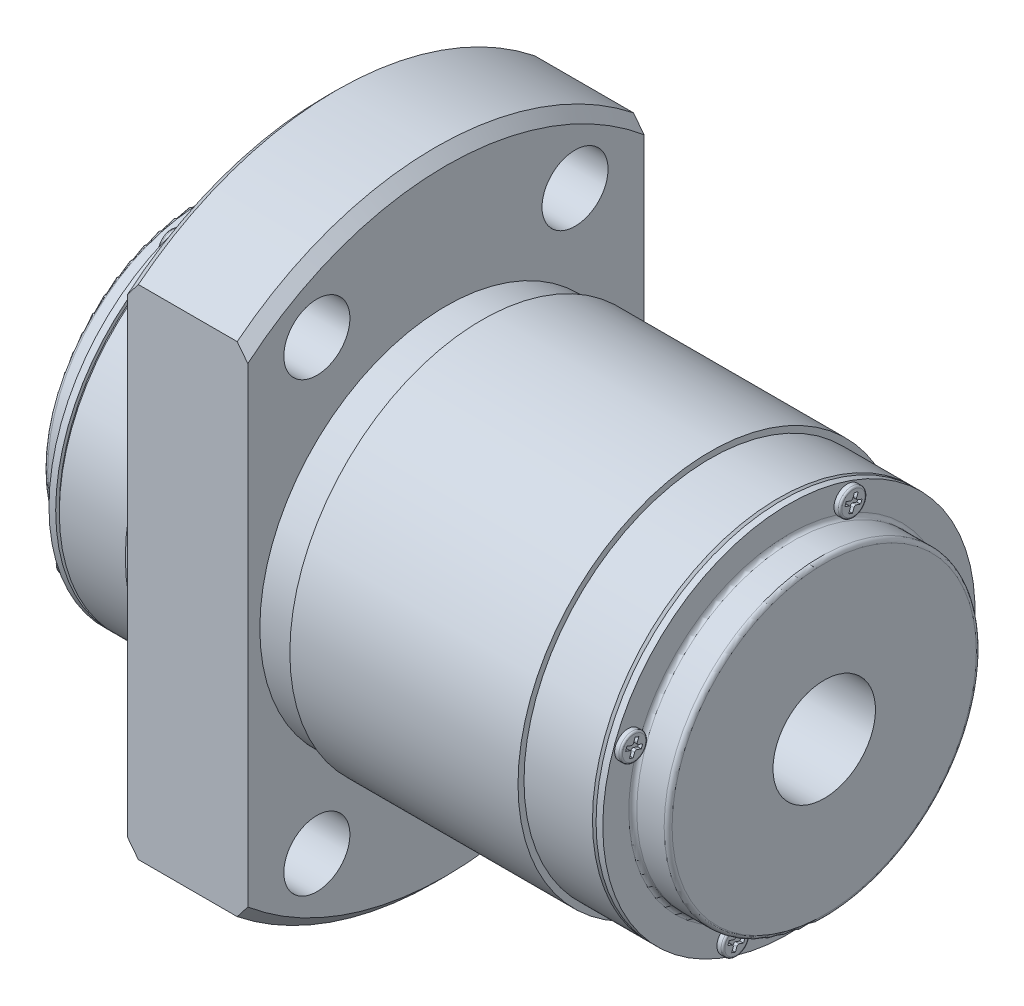
from build123d import *

# Parameters (mm, degrees)
SKETCH2_W           = 10
SKETCH2_H           = 2.75
SKETCH3_W           = 10
SKETCH3_H           = 2.75
SKETCH4_W           = 10
SKETCH4_H           = 2.75
SKETCH5_W           = 10
SKETCH5_H           = 2.75
SKETCH7_W           = 66
SKETCH7_H           = 106
SKETCH7_W_2         = 33
SKETCH7_H_2         = 55
CUT_EXTRUDE1_DEPTH  = 10
CUT_EXTRUDE2_DEPTH  = 0.3
CUT_EXTRUDE3_DEPTH  = 0.3
CUT_EXTRUDE4_DEPTH  = 0.3
CUT_EXTRUDE5_DEPTH  = 0.3
CUT_EXTRUDE6_DEPTH  = 0.3
CUT_EXTRUDE7_DEPTH  = 0.3
CUT_EXTRUDE8_DEPTH  = 0.3
CUT_EXTRUDE9_DEPTH  = 0.3
SKETCH24_R          = 7.5
SKETCH24_R_2        = 4.266666667
BOSS_EXTRUDE1_DEPTH = 52
SCALE1_SCALE        = 7.5


with BuildPart() as part:
    # Sketch1 → Revolve1 (revolve)
    with BuildSketch(Plane.XY):
        with BuildLine():
            Line((-3.5, 7.5), (48.5, 7.5))
            Line((48.5, 7.5), (48.5, 12.67))
            ThreePointArc((48.5, 12.67), (48.403345238, 12.903345238), (48.17, 13))
            Line((48.17, 13), (45.89, 13))
            ThreePointArc((45.89, 13), (45.656654762, 13.096654762), (45.56, 13.33))
            Line((45.56, 13.33), (45.56, 15.5))
            Line((45.56, 15.5), (45, 15.5))
            Line((45, 15.5), (45, 15.2))
            Line((45, 15.2), (44.7, 15.5))
            Line((44.7, 15.5), (39, 15.5))
            Line((39, 15.5), (39, 16))
            Line((39, 16), (20, 16))
            Line((20, 16), (20, 15.5))
            Line((20, 15.5), (17, 15.5))
            Line((17, 15.5), (17, 25.616666667))
            Line((17, 25.616666667), (16.116666667, 26.5))
            Line((16.116666667, 26.5), (7.883333333, 26.5))
            Line((7.883333333, 26.5), (7, 25.616666667))
            Line((7, 25.616666667), (7, 16))
            Line((7, 16), (6.3, 16))
            Line((6.3, 16), (6.3, 15.5))
            Line((6.3, 15.5), (0.3, 15.5))
            Line((0.3, 15.5), (0, 15.2))
            Line((0, 15.2), (0, 15.5))
            Line((0, 15.5), (-0.56, 15.5))
            Line((-0.56, 15.5), (-0.56, 13.33))
            ThreePointArc((-0.56, 13.33), (-0.656654762, 13.096654762), (-0.89, 13))
            Line((-0.89, 13), (-3.17, 13))
            ThreePointArc((-3.17, 13), (-3.403345238, 12.903345238), (-3.5, 12.67))
            Line((-3.5, 12.67), (-3.5, 7.5))
        make_face()
    revolve(axis=Axis((45, 0, 0), (-1, 0, 0)))

    # Sketch2 → Cut-Revolve1 (revolve, cut)
    with BuildSketch(Plane(origin=(0, 0, 0), x_dir=(1, 0, 0), z_dir=(0, -0.5, 0.866025404))):
        with Locations((12, 22.875)):
            Rectangle(SKETCH2_W, SKETCH2_H)
    revolve(axis=Axis((17, 18.619546181, 10.75), (-1, 0, 0)), mode=Mode.SUBTRACT)

    # Sketch3 → Cut-Revolve2 (revolve, cut)
    with BuildSketch(Plane(origin=(0, 0, 0), x_dir=(1, 0, 0), z_dir=(0, -0.5, 0.866025404))):
        with Locations((12, -20.125)):
            Rectangle(SKETCH3_W, SKETCH3_H)
    revolve(axis=Axis((17, -18.619546181, -10.75), (-1, 0, 0)), mode=Mode.SUBTRACT)

    # Sketch4 → Cut-Revolve3 (revolve, cut)
    with BuildSketch(Plane(origin=(0, 0, 0), x_dir=(1, 0, 0), z_dir=(0, 0.5, 0.866025404))):
        with Locations((12, 22.875)):
            Rectangle(SKETCH4_W, SKETCH4_H)
    revolve(axis=Axis((17, 18.619546181, -10.75), (-1, 0, 0)), mode=Mode.SUBTRACT)

    # Sketch5 → Cut-Revolve4 (revolve, cut)
    with BuildSketch(Plane(origin=(0, 0, 0), x_dir=(1, 0, 0), z_dir=(0, 0.5, 0.866025404))):
        with Locations((12, -20.125)):
            Rectangle(SKETCH5_W, SKETCH5_H)
    revolve(axis=Axis((17, -18.619546181, 10.75), (-1, 0, 0)), mode=Mode.SUBTRACT)

    # Sketch6 → Cut-Revolve5 (revolve, cut)
    with BuildSketch(Plane.XY):
        Polygon((12, -5.5), (14.4585, -6.919415637), (14.4585, -25.9585), (15, -26.5), (12, -26.5), align=None)
    revolve(axis=Axis((12, -26.5, 0), (0, 1, 0)), mode=Mode.SUBTRACT)

    # Sketch7 → Cut-Extrude1 (cut)
    with BuildSketch(Plane(origin=(17, 0, 0), x_dir=(0, 0, -1), z_dir=(1, 0, 0))):
        Rectangle(SKETCH7_W, SKETCH7_H)
        Rectangle(SKETCH7_W_2, SKETCH7_H_2, mode=Mode.SUBTRACT)
    extrude(amount=-CUT_EXTRUDE1_DEPTH, mode=Mode.SUBTRACT)

    # Sketch8 → Revolve2 (revolve)
    with BuildSketch(Plane(origin=(0, 0, 0), x_dir=(1, 0, 0), z_dir=(0, -0.342020143, 0.939692621))):
        with BuildLine():
            Line((-1.06, 14.25), (-1.06, 15.17))
            ThreePointArc((-1.06, 15.17), (-1.001421356, 15.311421356), (-0.86, 15.37))
            Line((-0.86, 15.37), (-0.56, 15.37))
            Line((-0.56, 15.37), (-0.56, 14.25))
            Line((-0.56, 14.25), (-1.06, 14.25))
        make_face()
    revolve(axis=Axis((-0.56, 13.390619846, 4.873787042), (-1, 0, 0)))

    # Sketch9 → Revolve3 (revolve)
    with BuildSketch(Plane(origin=(0, -4.873787042, 13.390619846), x_dir=(1, 0, 0), z_dir=(0, -0.342020143, 0.939692621))):
        with BuildLine():
            Line((-1.06, 0), (-1.06, 0.92))
            ThreePointArc((-1.06, 0.92), (-1.001421356, 1.061421356), (-0.86, 1.12))
            Line((-0.86, 1.12), (-0.56, 1.12))
            Line((-0.56, 1.12), (-0.56, 0))
            Line((-0.56, 0), (-1.06, 0))
        make_face()
    revolve(axis=Axis((-0.56, -4.873787042, 13.390619846), (-1, 0, 0)))

    # Sketch10 → Revolve4 (revolve)
    with BuildSketch(Plane(origin=(0, 0, 0), x_dir=(1, 0, 0), z_dir=(0, -0.342020143, 0.939692621))):
        with BuildLine():
            Line((-1.06, -14.25), (-1.06, -13.33))
            ThreePointArc((-1.06, -13.33), (-1.001421356, -13.188578644), (-0.86, -13.13))
            Line((-0.86, -13.13), (-0.56, -13.13))
            Line((-0.56, -13.13), (-0.56, -14.25))
            Line((-0.56, -14.25), (-1.06, -14.25))
        make_face()
    revolve(axis=Axis((-0.56, -13.390619846, -4.873787042), (-1, 0, 0)))

    # Sketch11 → Revolve5 (revolve)
    with BuildSketch(Plane(origin=(0, 4.873787042, -13.390619846), x_dir=(1, 0, 0), z_dir=(0, -0.342020143, 0.939692621))):
        with BuildLine():
            Line((-1.06, 0), (-1.06, 0.92))
            ThreePointArc((-1.06, 0.92), (-1.001421356, 1.061421356), (-0.86, 1.12))
            Line((-0.86, 1.12), (-0.56, 1.12))
            Line((-0.56, 1.12), (-0.56, 0))
            Line((-0.56, 0), (-1.06, 0))
        make_face()
    revolve(axis=Axis((-0.56, 4.873787042, -13.390619846), (-1, 0, 0)))

    # Sketch12 → Revolve6 (revolve)
    with BuildSketch(Plane(origin=(0, 0, 0), x_dir=(1, 0, 0), z_dir=(0, 0.342020143, 0.939692621))):
        with BuildLine():
            Line((45.56, 14.25), (45.56, 15.37))
            Line((45.56, 15.37), (45.91, 15.37))
            ThreePointArc((45.91, 15.37), (46.016066017, 15.326066017), (46.06, 15.22))
            Line((46.06, 15.22), (46.06, 14.25))
            Line((46.06, 14.25), (45.56, 14.25))
        make_face()
    revolve(axis=Axis((46.06, 13.390619846, -4.873787042), (-1, 0, 0)))

    # Sketch13 → Revolve7 (revolve)
    with BuildSketch(Plane(origin=(0, -4.873787042, -13.390619846), x_dir=(1, 0, 0), z_dir=(0, 0.342020143, 0.939692621))):
        with BuildLine():
            Line((45.56, 0), (45.56, 1.12))
            Line((45.56, 1.12), (45.91, 1.12))
            ThreePointArc((45.91, 1.12), (46.016066017, 1.076066017), (46.06, 0.97))
            Line((46.06, 0.97), (46.06, 0))
            Line((46.06, 0), (45.56, 0))
        make_face()
    revolve(axis=Axis((46.06, -4.873787042, -13.390619846), (-1, 0, 0)))

    # Sketch14 → Revolve8 (revolve)
    with BuildSketch(Plane(origin=(0, 0, 0), x_dir=(1, 0, 0), z_dir=(0, 0.342020143, 0.939692621))):
        with BuildLine():
            Line((45.56, -14.25), (45.56, -13.13))
            Line((45.56, -13.13), (45.91, -13.13))
            ThreePointArc((45.91, -13.13), (46.016066017, -13.173933983), (46.06, -13.28))
            Line((46.06, -13.28), (46.06, -14.25))
            Line((46.06, -14.25), (45.56, -14.25))
        make_face()
    revolve(axis=Axis((46.06, -13.390619846, 4.873787042), (-1, 0, 0)))

    # Sketch15 → Revolve9 (revolve)
    with BuildSketch(Plane(origin=(0, 4.873787042, 13.390619846), x_dir=(1, 0, 0), z_dir=(0, 0.342020143, 0.939692621))):
        with BuildLine():
            Line((45.56, 0), (45.56, 1.12))
            Line((45.56, 1.12), (45.91, 1.12))
            ThreePointArc((45.91, 1.12), (46.016066017, 1.076066017), (46.06, 0.97))
            Line((46.06, 0.97), (46.06, 0))
            Line((46.06, 0), (45.56, 0))
        make_face()
    revolve(axis=Axis((46.06, 4.873787042, 13.390619846), (-1, 0, 0)))

    # Sketch16 → Cut-Extrude2 (cut)
    with BuildSketch(Plane(origin=(46.06, 0, 0), x_dir=(0, 0, -1), z_dir=(1, 0, 0))):
        with BuildLine():
            Line((4.164267347, 13.473274563), (4.511953617, 13.34672711))
            ThreePointArc((4.511953617, 13.34672711), (4.60223964, 13.263995213), (4.607581213, 13.141653068))
            Line((4.607581213, 13.141653068), (4.48103376, 12.793966798))
            Line((4.48103376, 12.793966798), (4.791132325, 12.681100151))
            Line((4.791132325, 12.681100151), (4.917679778, 13.028786421))
            ThreePointArc((4.917679778, 13.028786421), (5.000411676, 13.119072444), (5.12275382, 13.124414017))
            Line((5.12275382, 13.124414017), (5.47044009, 12.997866564))
            Line((5.47044009, 12.997866564), (5.583306737, 13.307965129))
            Line((5.583306737, 13.307965129), (5.235620468, 13.434512582))
            ThreePointArc((5.235620468, 13.434512582), (5.145334445, 13.517244479), (5.139992871, 13.639586624))
            Line((5.139992871, 13.639586624), (5.266540324, 13.987272894))
            Line((5.266540324, 13.987272894), (4.95644176, 14.100139541))
            Line((4.95644176, 14.100139541), (4.829894307, 13.752453272))
            ThreePointArc((4.829894307, 13.752453272), (4.747162409, 13.662167249), (4.624820264, 13.656825675))
            Line((4.624820264, 13.656825675), (4.277133995, 13.783373128))
            Line((4.277133995, 13.783373128), (4.164267347, 13.473274563))
        make_face()
    extrude(amount=-CUT_EXTRUDE2_DEPTH, mode=Mode.SUBTRACT)

    # Sketch17 → Cut-Extrude3 (cut)
    with BuildSketch(Plane(origin=(46.06, 0, 0), x_dir=(0, 0, -1), z_dir=(1, 0, 0))):
        with BuildLine():
            Line((-14.100139541, 4.95644176), (-13.752453272, 4.829894307))
            ThreePointArc((-13.752453272, 4.829894307), (-13.662167249, 4.747162409), (-13.656825675, 4.624820264))
            Line((-13.656825675, 4.624820264), (-13.783373128, 4.277133995))
            Line((-13.783373128, 4.277133995), (-13.473274563, 4.164267347))
            Line((-13.473274563, 4.164267347), (-13.34672711, 4.511953617))
            ThreePointArc((-13.34672711, 4.511953617), (-13.263995213, 4.60223964), (-13.141653068, 4.607581213))
            Line((-13.141653068, 4.607581213), (-12.793966798, 4.48103376))
            Line((-12.793966798, 4.48103376), (-12.681100151, 4.791132325))
            Line((-12.681100151, 4.791132325), (-13.028786421, 4.917679778))
            ThreePointArc((-13.028786421, 4.917679778), (-13.119072444, 5.000411676), (-13.124414017, 5.12275382))
            Line((-13.124414017, 5.12275382), (-12.997866564, 5.47044009))
            Line((-12.997866564, 5.47044009), (-13.307965129, 5.583306737))
            Line((-13.307965129, 5.583306737), (-13.434512582, 5.235620468))
            ThreePointArc((-13.434512582, 5.235620468), (-13.517244479, 5.145334445), (-13.639586624, 5.139992871))
            Line((-13.639586624, 5.139992871), (-13.987272894, 5.266540324))
            Line((-13.987272894, 5.266540324), (-14.100139541, 4.95644176))
        make_face()
    extrude(amount=-CUT_EXTRUDE3_DEPTH, mode=Mode.SUBTRACT)

    # Sketch18 → Cut-Extrude4 (cut)
    with BuildSketch(Plane(origin=(46.06, 0, 0), x_dir=(0, 0, -1), z_dir=(1, 0, 0))):
        with BuildLine():
            Line((-5.583306737, -13.307965129), (-5.235620468, -13.434512582))
            ThreePointArc((-5.235620468, -13.434512582), (-5.145334445, -13.517244479), (-5.139992871, -13.639586624))
            Line((-5.139992871, -13.639586624), (-5.266540324, -13.987272894))
            Line((-5.266540324, -13.987272894), (-4.95644176, -14.100139541))
            Line((-4.95644176, -14.100139541), (-4.829894307, -13.752453272))
            ThreePointArc((-4.829894307, -13.752453272), (-4.747162409, -13.662167249), (-4.624820264, -13.656825675))
            Line((-4.624820264, -13.656825675), (-4.277133995, -13.783373128))
            Line((-4.277133995, -13.783373128), (-4.164267347, -13.473274563))
            Line((-4.164267347, -13.473274563), (-4.511953617, -13.34672711))
            ThreePointArc((-4.511953617, -13.34672711), (-4.60223964, -13.263995213), (-4.607581213, -13.141653068))
            Line((-4.607581213, -13.141653068), (-4.48103376, -12.793966798))
            Line((-4.48103376, -12.793966798), (-4.791132325, -12.681100151))
            Line((-4.791132325, -12.681100151), (-4.917679778, -13.028786421))
            ThreePointArc((-4.917679778, -13.028786421), (-5.000411676, -13.119072444), (-5.12275382, -13.124414017))
            Line((-5.12275382, -13.124414017), (-5.47044009, -12.997866564))
            Line((-5.47044009, -12.997866564), (-5.583306737, -13.307965129))
        make_face()
    extrude(amount=-CUT_EXTRUDE4_DEPTH, mode=Mode.SUBTRACT)

    # Sketch19 → Cut-Extrude5 (cut)
    with BuildSketch(Plane(origin=(46.06, 0, 0), x_dir=(0, 0, -1), z_dir=(1, 0, 0))):
        with BuildLine():
            Line((12.681100151, -4.791132325), (13.028786421, -4.917679778))
            ThreePointArc((13.028786421, -4.917679778), (13.119072444, -5.000411676), (13.124414017, -5.12275382))
            Line((13.124414017, -5.12275382), (12.997866564, -5.47044009))
            Line((12.997866564, -5.47044009), (13.307965129, -5.583306737))
            Line((13.307965129, -5.583306737), (13.434512582, -5.235620468))
            ThreePointArc((13.434512582, -5.235620468), (13.517244479, -5.145334445), (13.639586624, -5.139992871))
            Line((13.639586624, -5.139992871), (13.987272894, -5.266540324))
            Line((13.987272894, -5.266540324), (14.100139541, -4.95644176))
            Line((14.100139541, -4.95644176), (13.752453272, -4.829894307))
            ThreePointArc((13.752453272, -4.829894307), (13.662167249, -4.747162409), (13.656825675, -4.624820264))
            Line((13.656825675, -4.624820264), (13.783373128, -4.277133995))
            Line((13.783373128, -4.277133995), (13.473274563, -4.164267347))
            Line((13.473274563, -4.164267347), (13.34672711, -4.511953617))
            ThreePointArc((13.34672711, -4.511953617), (13.263995213, -4.60223964), (13.141653068, -4.607581213))
            Line((13.141653068, -4.607581213), (12.793966798, -4.48103376))
            Line((12.793966798, -4.48103376), (12.681100151, -4.791132325))
        make_face()
    extrude(amount=-CUT_EXTRUDE5_DEPTH, mode=Mode.SUBTRACT)

    # Sketch20 → Cut-Extrude6 (cut)
    with BuildSketch(Plane(origin=(-1.06, 0, 0), x_dir=(0, 0, -1), z_dir=(1, 0, 0))):
        with BuildLine():
            Line((-5.583306737, 13.307965129), (-5.47044009, 12.997866564))
            Line((-5.47044009, 12.997866564), (-5.12275382, 13.124414017))
            ThreePointArc((-5.12275382, 13.124414017), (-5.000411676, 13.119072444), (-4.917679778, 13.028786421))
            Line((-4.917679778, 13.028786421), (-4.791132325, 12.681100151))
            Line((-4.791132325, 12.681100151), (-4.48103376, 12.793966798))
            Line((-4.48103376, 12.793966798), (-4.607581213, 13.141653068))
            ThreePointArc((-4.607581213, 13.141653068), (-4.60223964, 13.263995213), (-4.511953617, 13.34672711))
            Line((-4.511953617, 13.34672711), (-4.164267347, 13.473274563))
            Line((-4.164267347, 13.473274563), (-4.277133995, 13.783373128))
            Line((-4.277133995, 13.783373128), (-4.624820264, 13.656825675))
            ThreePointArc((-4.624820264, 13.656825675), (-4.747162409, 13.662167249), (-4.829894307, 13.752453272))
            Line((-4.829894307, 13.752453272), (-4.95644176, 14.100139541))
            Line((-4.95644176, 14.100139541), (-5.266540324, 13.987272894))
            Line((-5.266540324, 13.987272894), (-5.139992871, 13.639586624))
            ThreePointArc((-5.139992871, 13.639586624), (-5.145334445, 13.517244479), (-5.235620468, 13.434512582))
            Line((-5.235620468, 13.434512582), (-5.583306737, 13.307965129))
        make_face()
    extrude(amount=CUT_EXTRUDE6_DEPTH, mode=Mode.SUBTRACT)

    # Sketch21 → Cut-Extrude7 (cut)
    with BuildSketch(Plane(origin=(-1.06, 0, 0), x_dir=(0, 0, -1), z_dir=(1, 0, 0))):
        with BuildLine():
            Line((-14.100139541, -4.95644176), (-13.987272894, -5.266540324))
            Line((-13.987272894, -5.266540324), (-13.639586624, -5.139992871))
            ThreePointArc((-13.639586624, -5.139992871), (-13.517244479, -5.145334445), (-13.434512582, -5.235620468))
            Line((-13.434512582, -5.235620468), (-13.307965129, -5.583306737))
            Line((-13.307965129, -5.583306737), (-12.997866564, -5.47044009))
            Line((-12.997866564, -5.47044009), (-13.124414017, -5.12275382))
            ThreePointArc((-13.124414017, -5.12275382), (-13.119072444, -5.000411676), (-13.028786421, -4.917679778))
            Line((-13.028786421, -4.917679778), (-12.681100151, -4.791132325))
            Line((-12.681100151, -4.791132325), (-12.793966798, -4.48103376))
            Line((-12.793966798, -4.48103376), (-13.141653068, -4.607581213))
            ThreePointArc((-13.141653068, -4.607581213), (-13.263995213, -4.60223964), (-13.34672711, -4.511953617))
            Line((-13.34672711, -4.511953617), (-13.473274563, -4.164267347))
            Line((-13.473274563, -4.164267347), (-13.783373128, -4.277133995))
            Line((-13.783373128, -4.277133995), (-13.656825675, -4.624820264))
            ThreePointArc((-13.656825675, -4.624820264), (-13.662167249, -4.747162409), (-13.752453272, -4.829894307))
            Line((-13.752453272, -4.829894307), (-14.100139541, -4.95644176))
        make_face()
    extrude(amount=CUT_EXTRUDE7_DEPTH, mode=Mode.SUBTRACT)

    # Sketch22 → Cut-Extrude8 (cut)
    with BuildSketch(Plane(origin=(-1.06, 0, 0), x_dir=(0, 0, -1), z_dir=(1, 0, 0))):
        with BuildLine():
            Line((4.164267347, -13.473274563), (4.277133995, -13.783373128))
            Line((4.277133995, -13.783373128), (4.624820264, -13.656825675))
            ThreePointArc((4.624820264, -13.656825675), (4.747162409, -13.662167249), (4.829894307, -13.752453272))
            Line((4.829894307, -13.752453272), (4.95644176, -14.100139541))
            Line((4.95644176, -14.100139541), (5.266540324, -13.987272894))
            Line((5.266540324, -13.987272894), (5.139992871, -13.639586624))
            ThreePointArc((5.139992871, -13.639586624), (5.145334445, -13.517244479), (5.235620468, -13.434512582))
            Line((5.235620468, -13.434512582), (5.583306737, -13.307965129))
            Line((5.583306737, -13.307965129), (5.47044009, -12.997866564))
            Line((5.47044009, -12.997866564), (5.12275382, -13.124414017))
            ThreePointArc((5.12275382, -13.124414017), (5.000411676, -13.119072444), (4.917679778, -13.028786421))
            Line((4.917679778, -13.028786421), (4.791132325, -12.681100151))
            Line((4.791132325, -12.681100151), (4.48103376, -12.793966798))
            Line((4.48103376, -12.793966798), (4.607581213, -13.141653068))
            ThreePointArc((4.607581213, -13.141653068), (4.60223964, -13.263995213), (4.511953617, -13.34672711))
            Line((4.511953617, -13.34672711), (4.164267347, -13.473274563))
        make_face()
    extrude(amount=CUT_EXTRUDE8_DEPTH, mode=Mode.SUBTRACT)

    # Sketch23 → Cut-Extrude9 (cut)
    with BuildSketch(Plane(origin=(-1.06, 0, 0), x_dir=(0, 0, -1), z_dir=(1, 0, 0))):
        with BuildLine():
            Line((12.681100151, 4.791132325), (12.793966798, 4.48103376))
            Line((12.793966798, 4.48103376), (13.141653068, 4.607581213))
            ThreePointArc((13.141653068, 4.607581213), (13.263995213, 4.60223964), (13.34672711, 4.511953617))
            Line((13.34672711, 4.511953617), (13.473274563, 4.164267347))
            Line((13.473274563, 4.164267347), (13.783373128, 4.277133995))
            Line((13.783373128, 4.277133995), (13.656825675, 4.624820264))
            ThreePointArc((13.656825675, 4.624820264), (13.662167249, 4.747162409), (13.752453272, 4.829894307))
            Line((13.752453272, 4.829894307), (14.100139541, 4.95644176))
            Line((14.100139541, 4.95644176), (13.987272894, 5.266540324))
            Line((13.987272894, 5.266540324), (13.639586624, 5.139992871))
            ThreePointArc((13.639586624, 5.139992871), (13.517244479, 5.145334445), (13.434512582, 5.235620468))
            Line((13.434512582, 5.235620468), (13.307965129, 5.583306737))
            Line((13.307965129, 5.583306737), (12.997866564, 5.47044009))
            Line((12.997866564, 5.47044009), (13.124414017, 5.12275382))
            ThreePointArc((13.124414017, 5.12275382), (13.119072444, 5.000411676), (13.028786421, 4.917679778))
            Line((13.028786421, 4.917679778), (12.681100151, 4.791132325))
        make_face()
    extrude(amount=CUT_EXTRUDE9_DEPTH, mode=Mode.SUBTRACT)

    # Sketch24 → Boss-Extrude1 (add)
    with BuildSketch(Plane.ZY.offset(3.5)):
        Circle(SKETCH24_R)
        Circle(SKETCH24_R_2, mode=Mode.SUBTRACT)
    extrude(amount=-BOSS_EXTRUDE1_DEPTH)


with BuildPart() as part_1:
    # Scale1: scaled about (20.853453303, 0.142769019, -1e-07)
    add(part.part.scale(SCALE1_SCALE).moved(Location((-135.547446469, -0.927998623, 6.5e-07))))


solid = part_1.part
